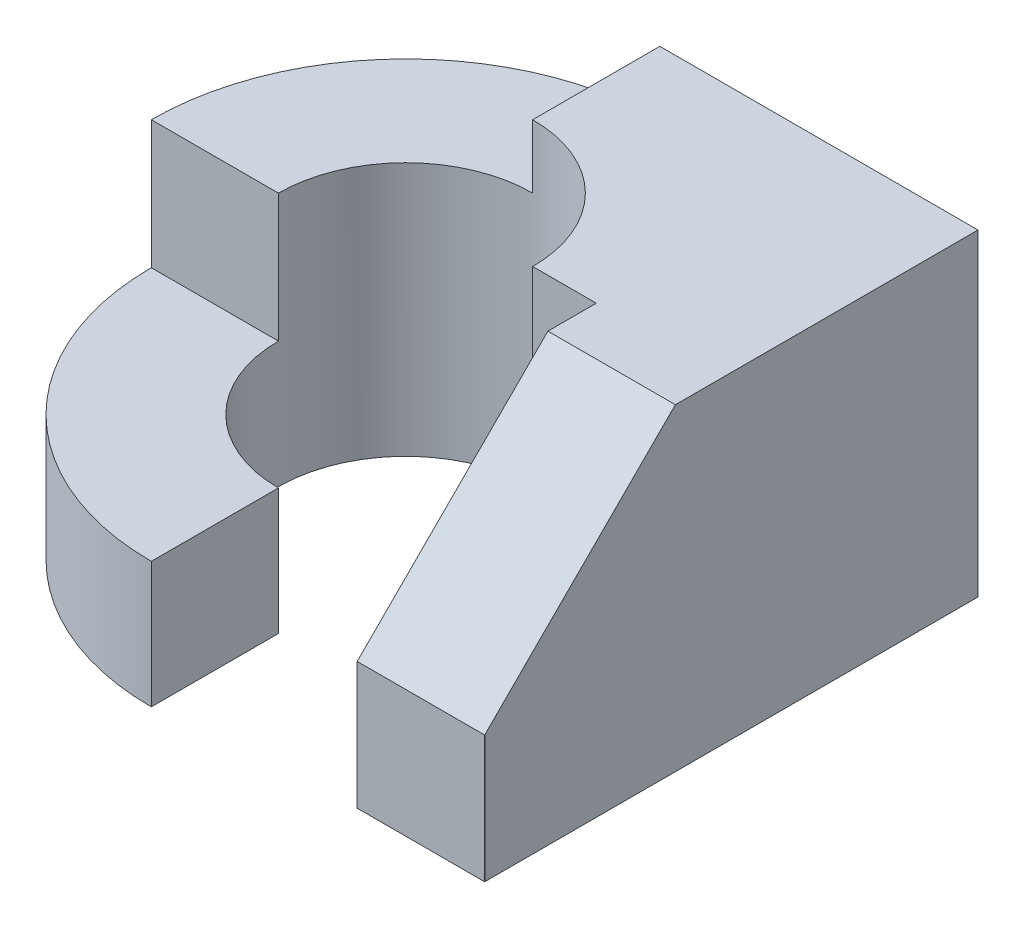
from build123d import *

# Parameters (mm, degrees)
BOSS_EXTRUDE1_DEPTH = 5
CUT_EXTRUDE1_DEPTH  = 5
CHAMFER1_SIZE       = 3


with BuildPart() as part:
    # Sketch1 → Boss-Extrude1 (new body)
    with BuildSketch(Plane(origin=(0, 0, 0), x_dir=(1, 0, 0), z_dir=(0, 1, 0))):
        with BuildLine():
            Line((0, -4), (0, -2))
            ThreePointArc((0, -2), (-1.414213562, 1.414213562), (2, 0))
            Line((2, 0), (3, 0))
            Line((3, 0), (3, -3.760972677))
            Line((3, -3.760972677), (4.998650065, -3.760972677))
            Line((4.998650065, -3.760972677), (5.005216321, -3.757452983))
            Line((5.005216321, -3.757452983), (5.005216321, 4))
            Line((5.005216321, 4), (0, 4))
            ThreePointArc((0, 4), (-4, 0), (0, -4))
        make_face()
    extrude(amount=BOSS_EXTRUDE1_DEPTH)

    # Sketch2 → Cut-Extrude1 (cut)
    with BuildSketch(Plane(origin=(0, 0, 0), x_dir=(0, 0, -1), z_dir=(1, 0, 0))):
        Polygon((4, 5), (0, 5), (0, 4.983533527), (-4, 4.983533527), (-4, 1.983533527), (0, 1.983533527), (0, 4), (4, 4), align=None)
    extrude(amount=-CUT_EXTRUDE1_DEPTH, mode=Mode.SUBTRACT)


with BuildPart() as cut_extrude1_kept_piece:
    # of the separate pieces the step leaves, the one the design keeps (cut_extrude1_pieces_kept)
    add(part.part.solids().sort_by_distance((0, 0, 4))[0])

    # Chamfer1
    chamfer1_edges = [cut_extrude1_kept_piece.edges().sort_by_distance(p)[0] for p in [
        (3.999325033, 5, 3.760972677),
    ]]
    chamfer(chamfer1_edges, length=CHAMFER1_SIZE)


solid = cut_extrude1_kept_piece.part
